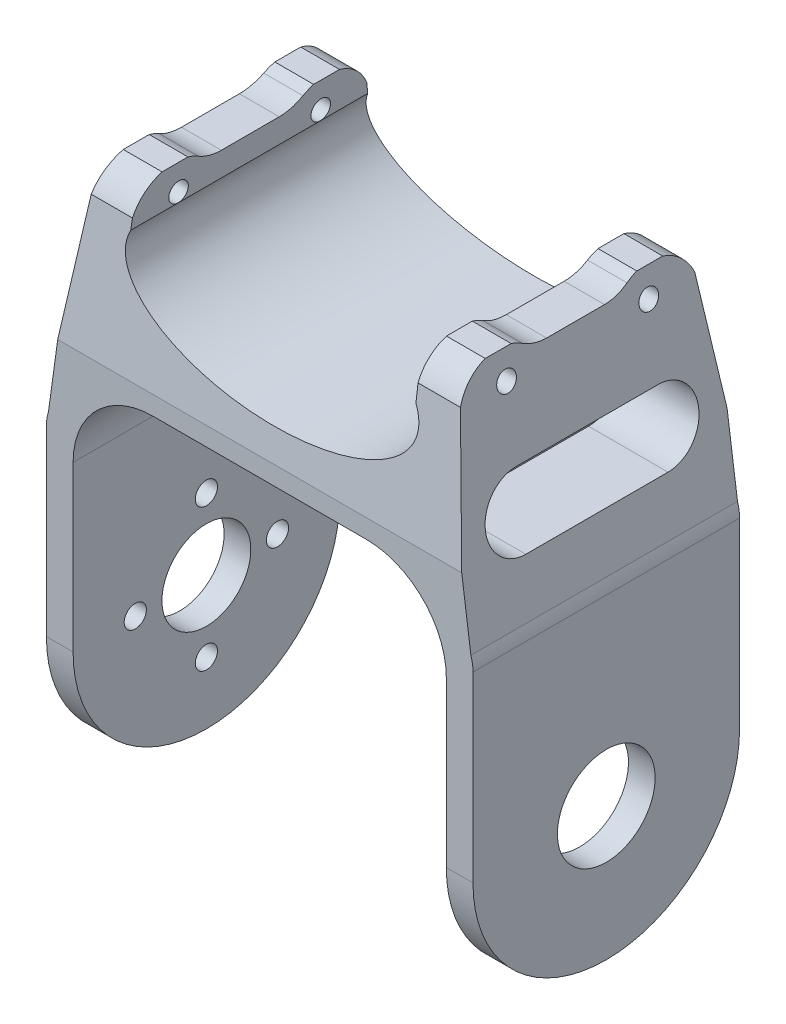
from build123d import *

# Parameters (mm, degrees)
EXTRUDE_1_DEPTH      = 30
SKETCH_3_R           = 5
CUT_EXTRUDE_5_DEPTH  = 56
CUT_EXTRUDE_12_DEPTH = 51
SKETCH_3_4_R         = 1.1
CUT_EXTRUDE_7_DEPTH  = 56
SKETCH_6_R           = 1.25
CUT_EXTRUDE_9_DEPTH  = 22
SKETCH_5_R           = 5.5
CUT_EXTRUDE_13_DEPTH = 10


with BuildPart() as part:
    # Эскиз1 → Бобышка-Вытянуть1 (new body)
    with BuildSketch(Plane.XY):
        with BuildLine():
            ThreePointArc((23.447094189, 8.182803621), (23.388195094, 8.947997617), (23.212885448, 9.69516392))
            Line((23.212885448, 9.69516392), (19.814400159, 34.41595773))
            Line((19.814400159, 34.41595773), (15.447094189, 34.41595773))
            Line((15.447094189, 34.41595773), (15.447094189, 29.601114652))
            add(Edge.make_bspline(
                [(-16.737207413, 30.306768931), (-21.154797026, 21.000420448), (-0.15838441, 20.540065316), (20.838028206, 20.079710184), (15.447094189, 29.601114652)],
                knots=[2.948852751, 2.948852751, 2.948852751, 4.755403061, 4.755403061, 6.56195337, 6.56195337, 6.56195337], degree=2, weights=[1, 0.619041122, 1, 0.619041122, 1]))
            Line((-16.737207413, 30.306768931), (-16.552905811, 34.41595773))
            Line((-16.552905811, 34.41595773), (-20.92021178, 34.41595773))
            Line((-20.92021178, 34.41595773), (-24.31869707, 9.69516392))
            ThreePointArc((-24.31869707, 9.69516392), (-24.494006715, 8.947997617), (-24.552905811, 8.182803621))
            Line((-24.552905811, 8.182803621), (-24.552905811, -27.36689041))
            Line((-24.552905811, -27.36689041), (-21.552905811, -27.36689041))
            Line((-21.552905811, -27.36689041), (-21.552905811, 5.955043958))
            Line((-21.552905811, 5.955043958), (-21.552905811, 6.111376347))
            ThreePointArc((-21.552905811, 6.111376347), (-18.916866841, 12.475337378), (-12.552905811, 15.111376347))
            Line((-12.552905811, 15.111376347), (11.447094189, 15.111376347))
            ThreePointArc((11.447094189, 15.111376347), (17.81105522, 12.475337378), (20.447094189, 6.111376347))
            Line((20.447094189, 6.111376347), (20.447094189, 5.955043958))
            Line((20.447094189, 5.955043958), (20.447094189, -27.36689041))
            Line((20.447094189, -27.36689041), (23.447094189, -27.36689041))
            Line((23.447094189, -27.36689041), (23.447094189, 8.182803621))
        make_face()
    extrude(amount=EXTRUDE_1_DEPTH)

    # Эскиз3 → Вырез-Вытянуть5 (cut)
    with BuildSketch(Plane(origin=(23.447094189, 0, 0), x_dir=(0, 0, -1), z_dir=(1, 0, 0))):
        with Locations(Location((-15, -12.36689041, 0), (0, 0, 90))):
            Circle(SKETCH_3_R)
        with BuildLine():
            ThreePointArc((-15, -27.36689041), (-25.606601718, -22.973492128), (-30, -12.36689041))
            Line((-30, -12.36689041), (-30, -27.36689041))
            Line((-30, -27.36689041), (-15, -27.36689041))
        make_face()
        with BuildLine():
            ThreePointArc((0, -12.36689041), (-4.393398282, -22.973492128), (-15, -27.36689041))
            Line((-15, -27.36689041), (0, -27.36689041))
            Line((0, -27.36689041), (0, -12.36689041))
        make_face()
    extrude(amount=-CUT_EXTRUDE_5_DEPTH, mode=Mode.SUBTRACT)

    # Эскиз2 → Вырез-Вытянуть12 (cut)
    with BuildSketch(Plane(origin=(23.447094189, 0, 0), x_dir=(0, 0, -1), z_dir=(1, 0, 0))):
        with BuildLine():
            ThreePointArc((-23.527450038, 34.63310959), (-26.347454746, 33.761980313), (-28.184823989, 31.45213897))
            Line((-28.184823989, 31.45213897), (-30.35352757, 14.45213897))
            Line((-30.35352757, 14.45213897), (-30.35352757, 34.95213897))
            Line((-30.35352757, 34.95213897), (-23.527450038, 34.63310959))
        make_face()
        with BuildLine():
            Line((-18.259623162, 33.13310959), (-15, 33.13310959))
            Line((-15, 33.13310959), (-15, 34.63310959))
            Line((-15, 34.63310959), (-23.527450038, 34.63310959))
            ThreePointArc((-23.527450038, 34.63310959), (-22.158143644, 34.441955605), (-20.8935366, 33.88310959))
            ThreePointArc((-20.8935366, 33.88310959), (-19.628929556, 33.324263575), (-18.259623162, 33.13310959))
        make_face()
        with BuildLine():
            Line((-15, 34.63310959), (-15, 33.13310959))
            Line((-15, 33.13310959), (-11.740376838, 33.13310959))
            ThreePointArc((-11.740376838, 33.13310959), (-10.371070444, 33.324263575), (-9.1064634, 33.88310959))
            ThreePointArc((-9.1064634, 33.88310959), (-7.841856356, 34.441955605), (-6.472549962, 34.63310959))
            Line((-6.472549962, 34.63310959), (-15, 34.63310959))
        make_face()
        with BuildLine():
            Line((0.509110945, 34.95310959), (-6.472549962, 34.63310959))
            ThreePointArc((-6.472549962, 34.63310959), (-3.652545254, 33.761980313), (-1.815176011, 31.45213897))
            Line((-1.815176011, 31.45213897), (0.509110945, 14.45310959))
            Line((0.509110945, 14.45310959), (0.509110945, 34.95310959))
        make_face()
    extrude(amount=-CUT_EXTRUDE_12_DEPTH, mode=Mode.SUBTRACT)

    # Эскиз3<4> → Вырез-Вытянуть7 (cut)
    with BuildSketch(Plane(origin=(23.447094189, 0, 0), x_dir=(0, 0, -1), z_dir=(1, 0, 0))):
        with Locations(Location((-23, 31.41595774, 0), (0, 0, 270))):
            Circle(SKETCH_3_4_R)
        with Locations(Location((-7, 31.41595774, 0), (0, 0, 270))):
            Circle(SKETCH_3_4_R)
    extrude(amount=-CUT_EXTRUDE_7_DEPTH, mode=Mode.SUBTRACT)

    # Эскиз6 → Вырез-Вытянуть9 (cut)
    with BuildSketch(Plane.ZY.offset(24.552905811)):
        with Locations(Location((15, -4.36689041, 0), (0, 0, 270))):
            Circle(SKETCH_6_R)
        with Locations(Location((7, -12.36689041, 0), (0, 0, 270))):
            Circle(SKETCH_6_R)
        with Locations(Location((23, -12.36689041, 0), (0, 0, 270))):
            Circle(SKETCH_6_R)
        with Locations(Location((15, -20.36689041, 0), (0, 0, 270))):
            Circle(SKETCH_6_R)
    extrude(amount=-CUT_EXTRUDE_9_DEPTH, mode=Mode.SUBTRACT)

    # Эскиз5 → Вырез-Вытянуть13 (cut)
    with BuildSketch(Plane(origin=(23.447094189, 0, 0), x_dir=(0, 0, -1), z_dir=(1, 0, 0))):
        with Locations(Location((-15, -12.36689041, 0), (0, 0, 90))):
            Circle(SKETCH_5_R)
        with BuildLine():
            Line((-15, 23.63310959), (-23, 23.63310959))
            ThreePointArc((-23, 23.63310959), (-27, 19.63310959), (-23, 15.63310959))
            Line((-23, 15.63310959), (-7, 15.63310959))
            ThreePointArc((-7, 15.63310959), (-3, 19.63310959), (-7, 23.63310959))
            Line((-7, 23.63310959), (-15, 23.63310959))
        make_face()
    extrude(amount=-CUT_EXTRUDE_13_DEPTH, mode=Mode.SUBTRACT)


solid = part.part
